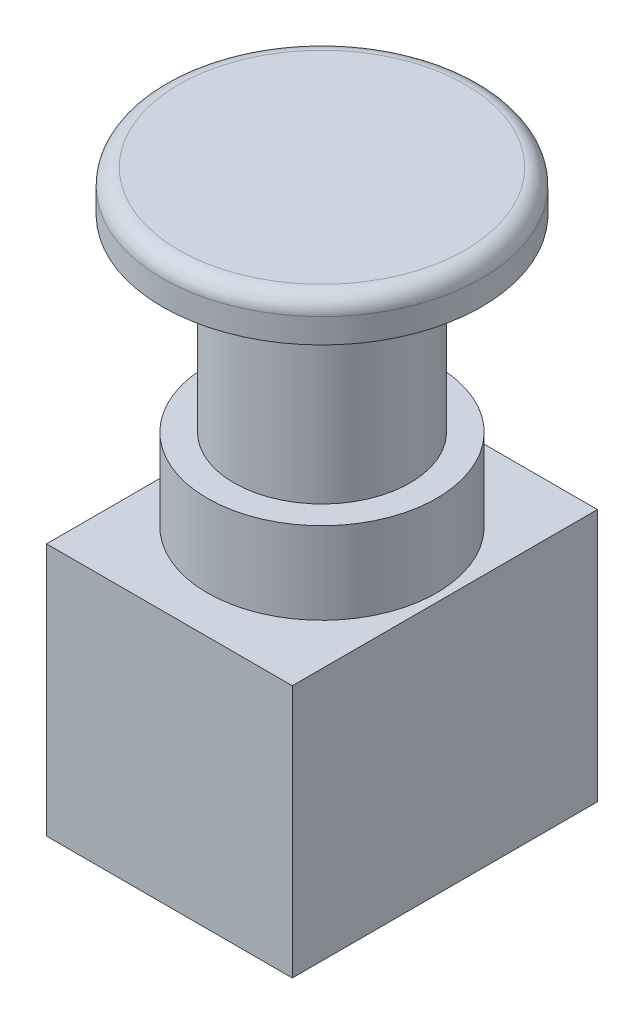
from build123d import *

# Parameters (mm, degrees)
SKETCH1_W           = 30
SKETCH1_H           = 37.25
BOSS_EXTRUDE1_DEPTH = 30.9
SKETCH2_R           = 14
BOSS_EXTRUDE2_DEPTH = 10
SKETCH3_R           = 10.75
BOSS_EXTRUDE3_DEPTH = 23
SKETCH4_R           = 19.5
BOSS_EXTRUDE4_DEPTH = 5
FILLET1_R           = 2


with BuildPart() as part:
    # Sketch1 → Boss-Extrude1 (new body)
    with BuildSketch(Plane(origin=(0, 0, 0), x_dir=(1, 0, 0), z_dir=(0, 1, 0))):
        Rectangle(SKETCH1_W, SKETCH1_H)
    extrude(amount=BOSS_EXTRUDE1_DEPTH)

    # Sketch2 → Boss-Extrude2 (add)
    with BuildSketch(Plane(origin=(0, 30.9, 0), x_dir=(1, 0, 0), z_dir=(0, 1, 0))):
        Circle(SKETCH2_R)
    extrude(amount=BOSS_EXTRUDE2_DEPTH)

    # Sketch3 → Boss-Extrude3 (add)
    with BuildSketch(Plane(origin=(0, 40.9, 0), x_dir=(1, 0, 0), z_dir=(0, 1, 0))):
        Circle(SKETCH3_R)
    extrude(amount=BOSS_EXTRUDE3_DEPTH)


with BuildPart() as body_2:
    # Sketch4 → Boss-Extrude4 (new body)
    with BuildSketch(Plane(origin=(0, 63.9, 0), x_dir=(1, 0, 0), z_dir=(0, 1, 0))):
        Circle(SKETCH4_R)
    extrude(amount=BOSS_EXTRUDE4_DEPTH)

    # Fillet1
    fillet1_edges = [body_2.edges().sort_by_distance(p)[0] for p in [
        (-19.5, 68.9, 0),
    ]]
    fillet(fillet1_edges, radius=FILLET1_R)


solid = Compound([part.part, body_2.part])
